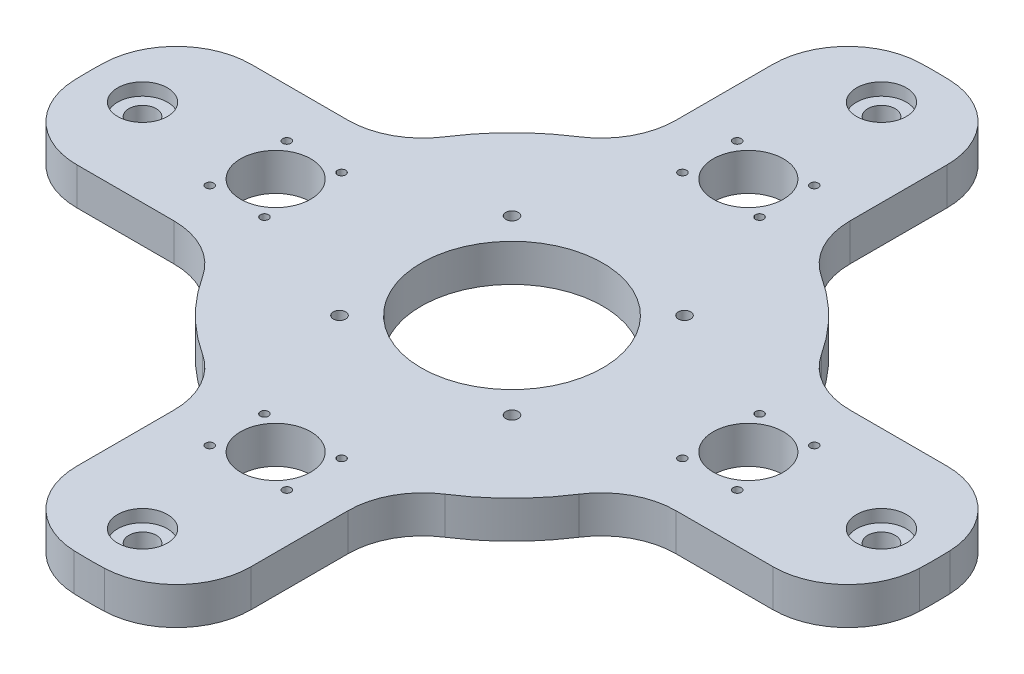
from build123d import *

# Parameters (mm, degrees)
SKETCH1_R             = 36.515
BOSS_EXTRUDE1_DEPTH   = 15
FILLET1_R             = 30
M6_TAPPED_HOLE1_D     = 5
SKETCH4_R             = 10
CUT_EXTRUDE1_DEPTH    = 5
M10_CLEARANCE_HOLE1_D = 11
CIRPATTERN1_COUNT     = 4
SKETCH7_R             = 14.1
CUT_EXTRUDE2_DEPTH    = 16
CIRPATTERN2_COUNT     = 4
M4_TAPPED_HOLE1_D     = 3.3
CIRPATTERN3_COUNT     = 4


with BuildPart() as part:
    # Sketch1 → Boss-Extrude1 (new body)
    with BuildSketch(Plane(origin=(0, 0, 0), x_dir=(1, 0, 0), z_dir=(0, 1, 0))):
        with BuildLine():
            Line((-35, 166.358047596), (-35, 82.915619759))
            ThreePointArc((-35, 82.915619759), (-63.639610307, 63.639610307), (-82.915619759, 35))
            Line((-82.915619759, 35), (-166.358047596, 35))
            ThreePointArc((-166.358047596, 35), (-170, 0), (-166.358047596, -35))
            Line((-166.358047596, -35), (-82.915619759, -35))
            ThreePointArc((-82.915619759, -35), (-63.639610307, -63.639610307), (-35, -82.915619759))
            Line((-35, -82.915619759), (-35, -166.358047596))
            ThreePointArc((-35, -166.358047596), (0, -170), (35, -166.358047596))
            Line((35, -166.358047596), (35, -82.915619759))
            ThreePointArc((35, -82.915619759), (63.639610307, -63.639610307), (82.915619759, -35))
            Line((82.915619759, -35), (166.358047596, -35))
            ThreePointArc((166.358047596, -35), (170, 0), (166.358047596, 35))
            Line((166.358047596, 35), (82.915619759, 35))
            ThreePointArc((82.915619759, 35), (63.639610307, 63.639610307), (35, 82.915619759))
            Line((35, 82.915619759), (35, 166.358047596))
            ThreePointArc((35, 166.358047596), (0, 170), (-35, 166.358047596))
        make_face()
        Circle(SKETCH1_R, mode=Mode.SUBTRACT)
    extrude(amount=BOSS_EXTRUDE1_DEPTH)

    # Fillet1
    fillet1_edges = [part.edges().sort_by_distance(p)[0] for p in [
        (-166.358047596, 7.5, 35),
        (-166.358047596, 7.5, -35),
        (-82.915619759, 7.5, -35),
        (-35, 7.5, -82.915619759),
        (-35, 7.5, -166.358047596),
        (35, 7.5, -166.358047596),
        (35, 7.5, -82.915619759),
        (82.915619759, 7.5, -35),
        (166.358047596, 7.5, -35),
        (166.358047596, 7.5, 35),
        (82.915619759, 7.5, 35),
        (35, 7.5, 82.915619759),
        (35, 7.5, 166.358047596),
        (-35, 7.5, 166.358047596),
        (-35, 7.5, 82.915619759),
        (-82.915619759, 7.5, 35),
    ]]
    fillet(fillet1_edges, radius=FILLET1_R)

    # M6 Tapped Hole1 (through all)
    with Locations(Plane.XZ):
        with Locations((-34.67, -34.67), (34.67, -34.67), (34.67, 34.67), (-34.67, 34.67)):
            Hole(M6_TAPPED_HOLE1_D / 2)

    # Sketch4 → Cut-Extrude1 (cut)
    with BuildSketch(Plane(origin=(0, 15, 0), x_dir=(1, 0, 0), z_dir=(0, 1, 0))):
        with Locations((0, 148.5)):
            Circle(SKETCH4_R)
    cut_extrude1 = extrude(amount=-CUT_EXTRUDE1_DEPTH, mode=Mode.SUBTRACT)

    # M10 Clearance Hole1 (through all)
    with Locations(Plane(origin=(0, 0, 0), x_dir=(-1, 0, 0), z_dir=(0, -1, 0))):
        with Locations((0, 148.5)):
            m10_clearance_hole1 = Hole(M10_CLEARANCE_HOLE1_D / 2)

    # CirPattern1: Cut-Extrude1, M10 Clearance Hole1 ×4 about axis
    cirpattern1_axis = Axis((0, 0, 0), (0, 1, 0))
    for i in range(1, CIRPATTERN1_COUNT):
        add(cut_extrude1.rotate(cirpattern1_axis, i * 360 / CIRPATTERN1_COUNT), mode=Mode.SUBTRACT)
        add(m10_clearance_hole1.rotate(cirpattern1_axis, i * 360 / CIRPATTERN1_COUNT), mode=Mode.SUBTRACT)

    # Sketch7 → Cut-Extrude2 (cut, through all)
    with BuildSketch(Plane(origin=(0, 15, 0), x_dir=(1, 0, 0), z_dir=(0, 1, 0))):
        with Locations((0, 95)):
            Circle(SKETCH7_R)
    cut_extrude2 = extrude(amount=-CUT_EXTRUDE2_DEPTH, mode=Mode.SUBTRACT)

    # CirPattern2: Cut-Extrude2 ×4 about axis
    cirpattern2_axis = Axis((0, 0, 0), (0, 1, 0))
    for i in range(1, CIRPATTERN2_COUNT):
        add(cut_extrude2.rotate(cirpattern2_axis, i * 360 / CIRPATTERN2_COUNT), mode=Mode.SUBTRACT)

    # M4 Tapped Hole1 (through all)
    with Locations(Plane(origin=(0, 15, 0), x_dir=(1, 0, 0), z_dir=(0, 1, 0))):
        with Locations((-15.5, 106), (-15.5, 84), (15.5, 84), (15.5, 106)):
            m4_tapped_hole1 = Hole(M4_TAPPED_HOLE1_D / 2)

    # CirPattern3: M4 Tapped Hole1 ×4 about axis
    cirpattern3_axis = Axis((0, 0, 0), (0, 1, 0))
    for i in range(1, CIRPATTERN3_COUNT):
        add(m4_tapped_hole1.rotate(cirpattern3_axis, i * 360 / CIRPATTERN3_COUNT), mode=Mode.SUBTRACT)


solid = part.part
